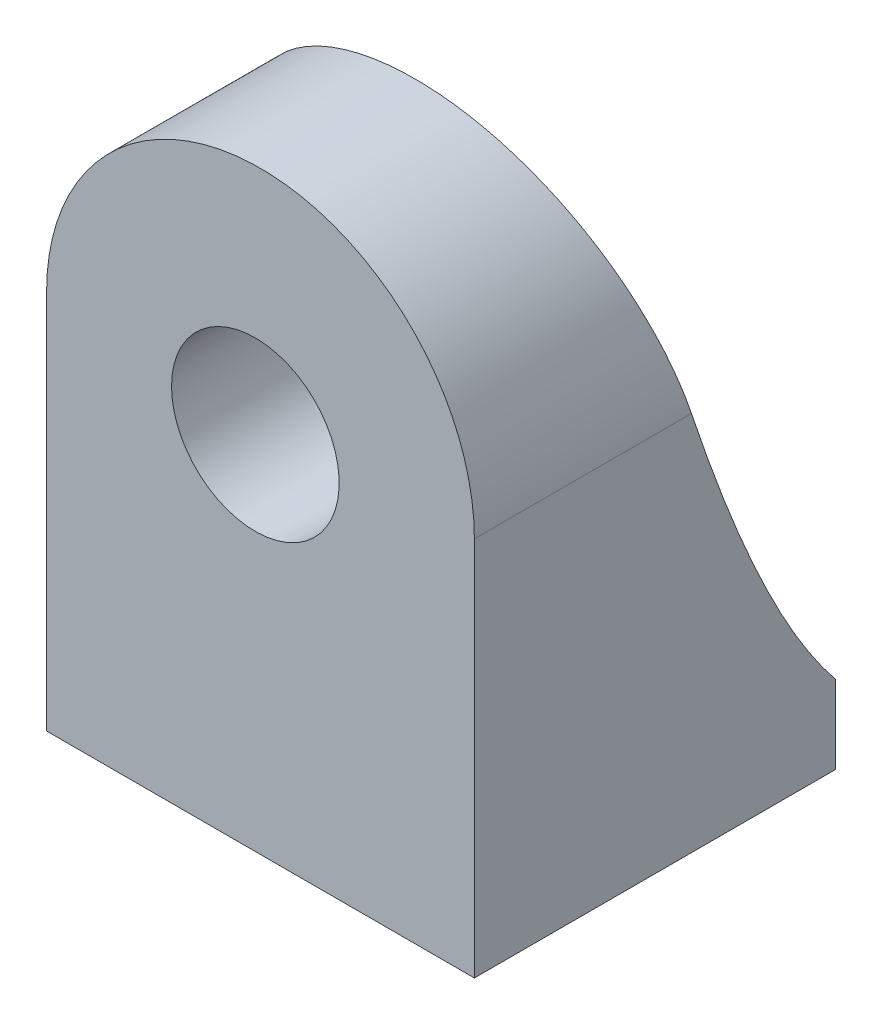
from build123d import *

# Parameters (mm, degrees)
BOSS_EXTRUDE1_DEPTH = 28
CUT_EXTRUDE1_DEPTH  = 34.177233055
CUT_EXTRUDE2_DEPTH  = 17
SKETCH7_R           = 6.5
CUT_EXTRUDE3_DEPTH  = 29.0000001
SKETCH8_R           = 7
CUT_EXTRUDE4_DEPTH  = 10


with BuildPart() as part:
    # Sketch1 → Boss-Extrude1 (new body)
    with BuildSketch(Plane.XY):
        with BuildLine():
            Line((-10.121301077, -4.327557758), (-10.121301077, -33.827557937))
            Line((-10.121301077, -33.827557937), (23.055931978, -33.827557937))
            Line((23.055931978, -33.827557937), (23.055931978, -4.327557758))
            ThreePointArc((23.055931978, -4.327557758), (6.467315451, 12.261058769), (-10.121301077, -4.327557758))
        make_face()
    extrude(amount=BOSS_EXTRUDE1_DEPTH)

    # Sketch3 → Cut-Extrude1 (cut, through all)
    with BuildSketch(Plane(origin=(23.055931978, 0, 0), x_dir=(0, 0, -1), z_dir=(1, 0, 0))):
        with BuildLine():
            Line((0, -7.671360057), (0, -27.738941231))
            add(Edge.make_bspline(
                [(0, -27.738941231), (-8.213527787, -17.773605897), (-16, 12.261058769)],
                knots=[0, 0, 0, 1, 1, 1], degree=2))
            Line((-16, 12.261058769), (0, 12.261058769))
            Line((0, 12.261058769), (0, -7.671360057))
        make_face()
    extrude(amount=-CUT_EXTRUDE1_DEPTH, mode=Mode.SUBTRACT)

    # Sketch5 → Cut-Extrude2 (cut)
    with BuildSketch(Plane(origin=(0, 0, 0), x_dir=(-1, 0, 0), z_dir=(0, 0, -1))):
        with BuildLine():
            Line((-20.055931978, -28.827557937), (-20.055931978, -5.827557937))
            ThreePointArc((-20.055931978, -5.827557937), (-6.467315451, 7.76105859), (7.121301077, -5.827557937))
            Line((7.121301077, -5.827557937), (7.121301077, -28.827557937))
            Line((7.121301077, -28.827557937), (-20.055931978, -28.827557937))
        make_face()
    extrude(amount=-CUT_EXTRUDE2_DEPTH, mode=Mode.SUBTRACT)

    # Sketch7 → Cut-Extrude3 (cut, through all)
    with BuildSketch(Plane(origin=(0, 0, 0), x_dir=(-1, 0, 0), z_dir=(0, 0, -1))):
        with Locations((-6.068714161, -5.827557937)):
            Circle(SKETCH7_R)
    extrude(amount=-CUT_EXTRUDE3_DEPTH, mode=Mode.SUBTRACT)

    # Sketch8 → Cut-Extrude4 (cut)
    with BuildSketch(Plane(origin=(0, -28.827557937, 0), x_dir=(1, 0, 0), z_dir=(0, 1, 0))):
        with Locations((6.467315451, -8.5)):
            Circle(SKETCH8_R)
    extrude(amount=-CUT_EXTRUDE4_DEPTH, mode=Mode.SUBTRACT)


solid = part.part
